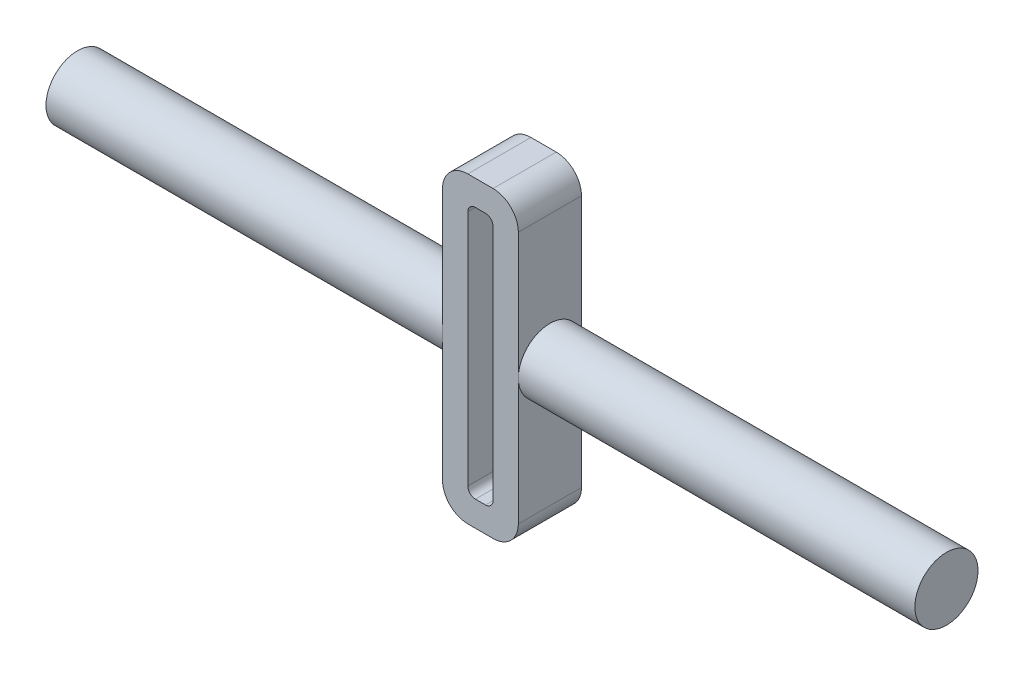
from build123d import *

# Parameters (mm, degrees)
SKETCH1_W           = 30
SKETCH1_H           = 120
BOSS_EXTRUDE1_DEPTH = 25
SKETCH2_W           = 10
SKETCH2_H           = 100
CUT_EXTRUDE1_DEPTH  = 26
SKETCH3_W           = 160
SKETCH3_H           = 12.5
SKETCH4_W           = 160
SKETCH4_H           = 12.5
FILLET1_R           = 3
FILLET2_R           = 10
SKETCH5_R           = 12.5
CUT_EXTRUDE2_DEPTH  = 3
SKETCH6_R           = 12.5
CUT_EXTRUDE3_DEPTH  = 3


with BuildPart() as part:
    # Sketch1 → Boss-Extrude1 (new body)
    with BuildSketch(Plane.XY.offset(25)):
        Rectangle(SKETCH1_W, SKETCH1_H)
    extrude(amount=-BOSS_EXTRUDE1_DEPTH)

    # Sketch2 → Cut-Extrude1 (cut, through all)
    with BuildSketch(Plane(origin=(0, 0, 0), x_dir=(-1, 0, 0), z_dir=(0, 0, -1))):
        Rectangle(SKETCH2_W, SKETCH2_H)
    extrude(amount=-CUT_EXTRUDE1_DEPTH, mode=Mode.SUBTRACT)

    # Sketch3 → Revolve1 (revolve)
    with BuildSketch(Plane.XY.offset(12.5)):
        with Locations((-95, 6.25)):
            Rectangle(SKETCH3_W, SKETCH3_H)
    revolve(axis=Axis((-175, 0, 12.5), (1, 0, 0)))

    # Sketch4 → Revolve2 (revolve)
    with BuildSketch(Plane(origin=(0, 0, 12.5), x_dir=(-1, 0, 0), z_dir=(0, 0, -1))):
        with Locations((-95, 6.25)):
            Rectangle(SKETCH4_W, SKETCH4_H)
    revolve(axis=Axis((175, 0, 12.5), (-1, 0, 0)))

    # Fillet1
    fillet1_edges = [part.edges().sort_by_distance(p)[0] for p in [
        (-5, -50, 12.5),
        (5, -50, 12.5),
        (5, 50, 12.5),
        (-5, 50, 12.5),
    ]]
    fillet(fillet1_edges, radius=FILLET1_R)

    # Fillet2
    fillet2_edges = [part.edges().sort_by_distance(p)[0] for p in [
        (-15, 60, 12.5),
        (15, 60, 12.5),
        (15, -60, 12.5),
        (-15, -60, 12.5),
    ]]
    fillet(fillet2_edges, radius=FILLET2_R)

    # Sketch5 → Cut-Extrude2 (cut)
    with BuildSketch(Plane(origin=(175, 0, 0), x_dir=(0, 0, -1), z_dir=(1, 0, 0))):
        with Locations((-12.5, 0)):
            Circle(SKETCH5_R)
    extrude(amount=-CUT_EXTRUDE2_DEPTH, mode=Mode.SUBTRACT)

    # Sketch6 → Cut-Extrude3 (cut)
    with BuildSketch(Plane.ZY.offset(175)):
        with Locations((12.5, 0)):
            Circle(SKETCH6_R)
    extrude(amount=-CUT_EXTRUDE3_DEPTH, mode=Mode.SUBTRACT)


solid = part.part
